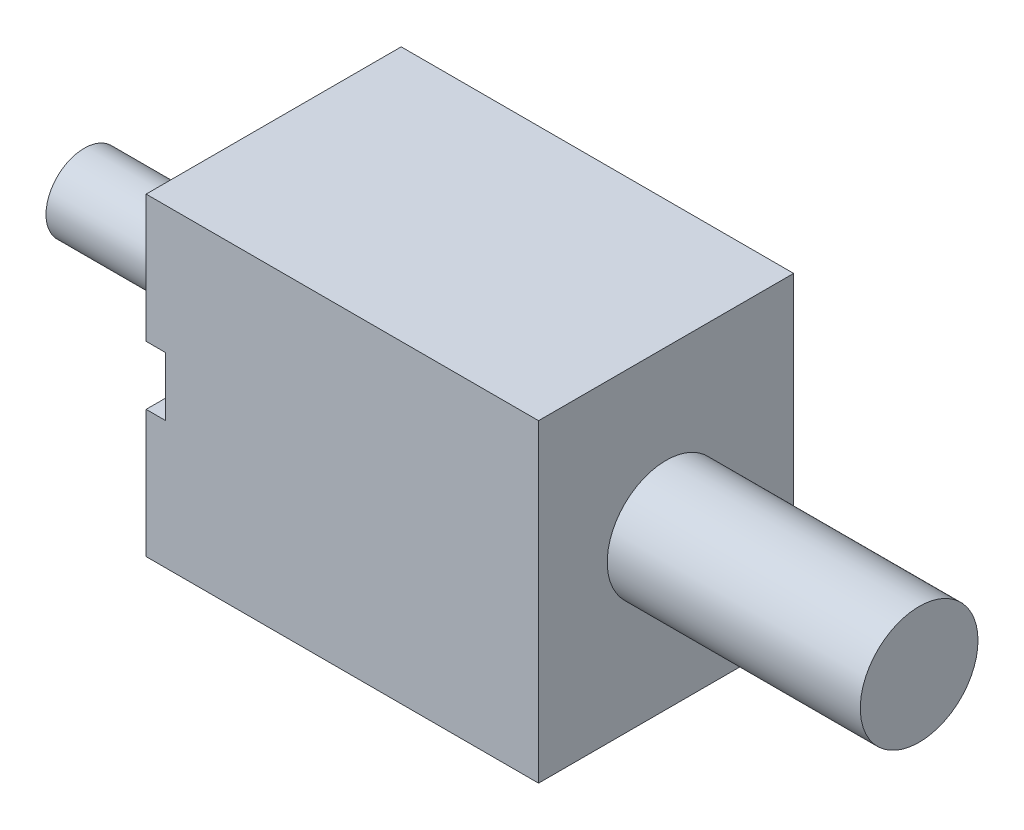
from build123d import *

# Parameters (mm, degrees)
SKETCH1_W           = 20
SKETCH1_H           = 13
BOSS_EXTRUDE1_DEPTH = 16
SKETCH2_R           = 1.95
BOSS_EXTRUDE2_DEPTH = 9.652509653
SKETCH3_R           = 3
BOSS_EXTRUDE3_DEPTH = 12.895752896
SKETCH4_W           = 1
SKETCH4_H           = 3
CUT_EXTRUDE1_DEPTH  = 1


with BuildPart() as part:
    # Sketch1 → Boss-Extrude1 (new body)
    with BuildSketch(Plane(origin=(0, 0, 0), x_dir=(1, 0, 0), z_dir=(0, 1, 0))):
        Rectangle(SKETCH1_W, SKETCH1_H)
    extrude(amount=BOSS_EXTRUDE1_DEPTH)

    # Sketch2 → Boss-Extrude2 (add)
    with BuildSketch(Plane.ZY.offset(10)):
        with Locations((0, 8)):
            Circle(SKETCH2_R)
    extrude(amount=BOSS_EXTRUDE2_DEPTH)

    # Sketch3 → Boss-Extrude3 (add)
    with BuildSketch(Plane(origin=(10, 0, 0), x_dir=(0, 0, -1), z_dir=(1, 0, 0))):
        with Locations((0, 8)):
            Circle(SKETCH3_R)
    extrude(amount=BOSS_EXTRUDE3_DEPTH)

    # Sketch4 → Cut-Extrude1 (cut)
    with BuildSketch(Plane.XY.offset(6.5)):
        with Locations((-9.5, 8)):
            Rectangle(SKETCH4_W, SKETCH4_H)
    extrude(amount=-CUT_EXTRUDE1_DEPTH, mode=Mode.SUBTRACT)


solid = part.part
